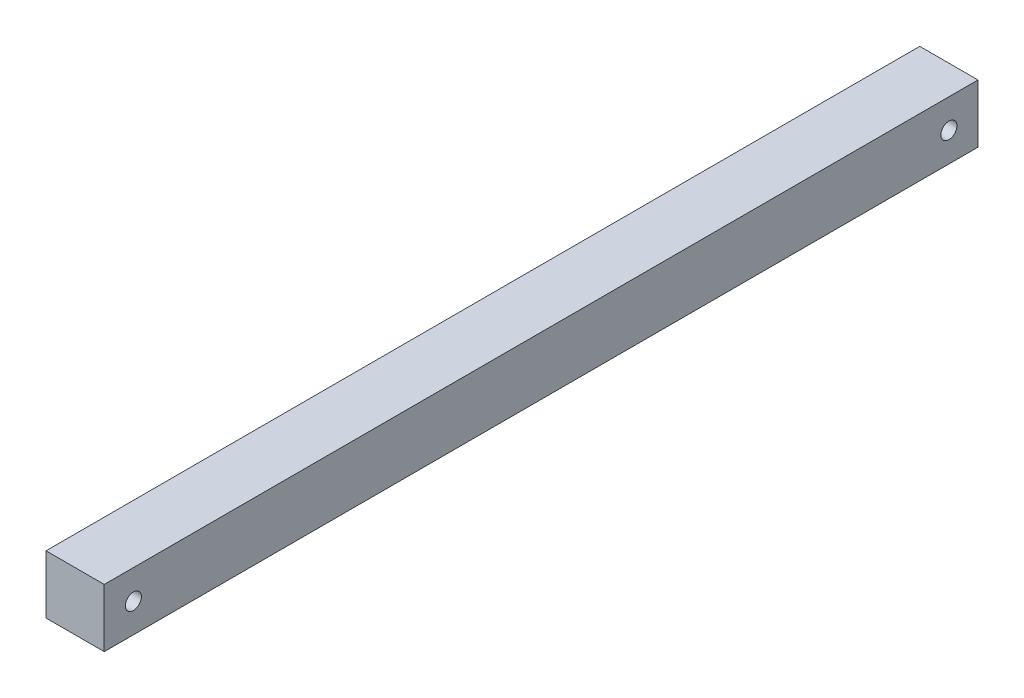
from build123d import *

# Parameters (mm, degrees)
SKETCH1_W           = 25.4
SKETCH1_H           = 25.4
BOSS_EXTRUDE1_DEPTH = 381
SKETCH10_R          = 3.5
CUT_EXTRUDE6_DEPTH  = 26.4


with BuildPart() as part:
    # Sketch1 → Boss-Extrude1 (new body)
    with BuildSketch(Plane.XY):
        Rectangle(SKETCH1_W, SKETCH1_H)
    extrude(amount=BOSS_EXTRUDE1_DEPTH)

    # Sketch10 → Cut-Extrude6 (cut, through all)
    with BuildSketch(Plane.ZY.offset(12.7)):
        with Locations((368.3, 0)):
            Circle(SKETCH10_R)
        with Locations((12.7, 0)):
            Circle(SKETCH10_R)
    extrude(amount=-CUT_EXTRUDE6_DEPTH, mode=Mode.SUBTRACT)


solid = part.part
